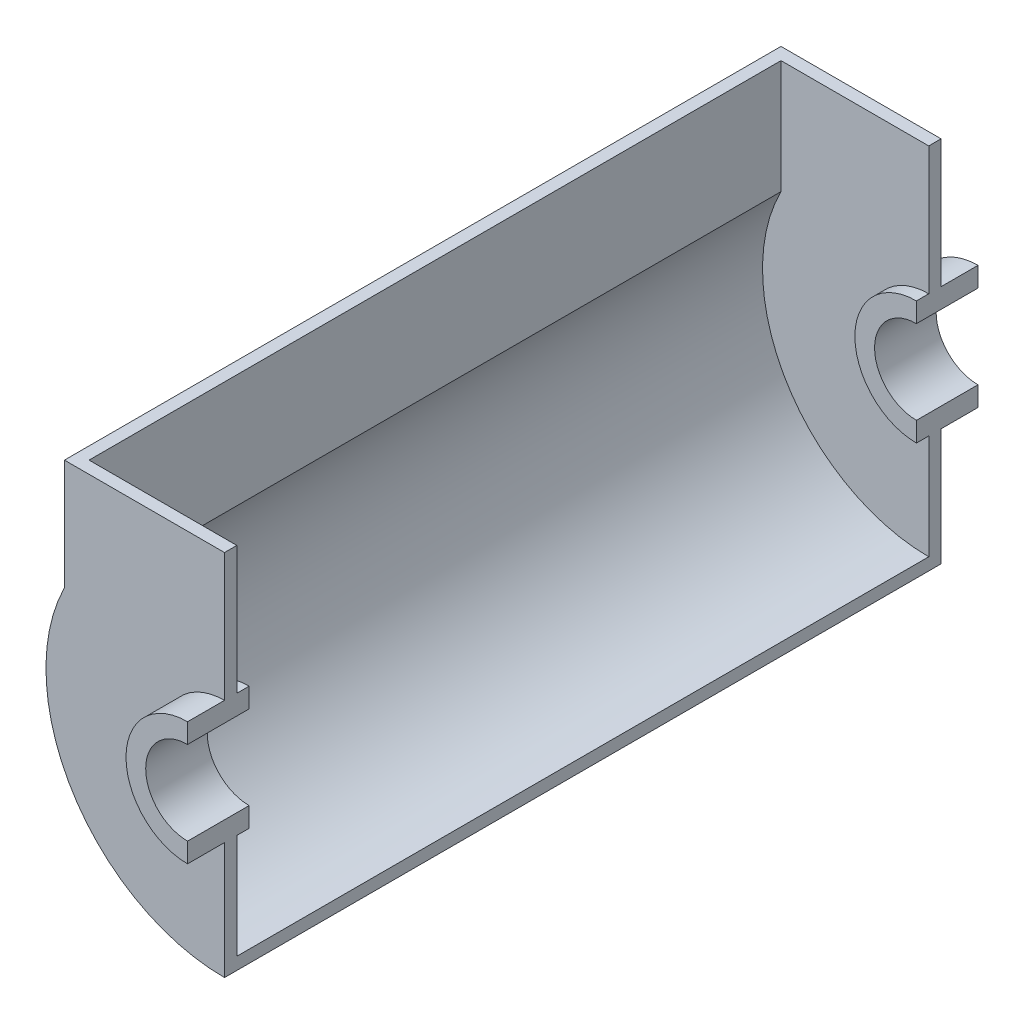
from build123d import *

# Parameters (mm, degrees)
BOSS_EXTRUDE1_DEPTH      = 20
BOSS_EXTRUDE1_DEPTH_BACK = 5
BOSS_EXTRUDE2_DEPTH      = 5
BOSS_EXTRUDE4_DEPTH      = 281


with BuildPart() as part:
    # Sketch1 → Boss-Extrude1 (new body, two sides)
    with BuildSketch(Plane.XY) as boss_extrude1_sk:
        with BuildLine():
            Line((0, 25), (0, 17))
            ThreePointArc((0, 17), (-17, 0), (0, -17))
            Line((0, -17), (0, -25))
            ThreePointArc((0, -25), (-25, 0), (0, 25))
        make_face()
    extrude(amount=BOSS_EXTRUDE1_DEPTH)
    extrude(boss_extrude1_sk.sketch, amount=-BOSS_EXTRUDE1_DEPTH_BACK)

    # Sketch2 → Boss-Extrude2 (add)
    with BuildSketch(Plane.XY):
        with BuildLine():
            Line((0, 25), (0, 77))
            Line((0, 77), (-65, 77))
            Line((-65, 77), (-65, 32.113081447))
            ThreePointArc((-65, 32.113081447), (-61.581037686, -38.262590053), (0, -72.5))
            Line((0, -72.5), (0, -25))
            ThreePointArc((0, -25), (-25, 0), (0, 25))
        make_face()
    extrude(amount=BOSS_EXTRUDE2_DEPTH)


with BuildPart() as body_2:
    # Mirror2: mirrored copy
    add(part.part.mirror(Plane.XY.offset(-140.5)))


with BuildPart() as part_1:
    add(part.part)

    add(body_2.part)  # Boss-Extrude4 merges body 2
    # Sketch3 → Boss-Extrude4 (add)
    with BuildSketch(Plane(origin=(0, 0, 0), x_dir=(-1, 0, 0), z_dir=(0, 0, -1))):
        with BuildLine():
            Line((60, 77), (60, 30.923292192))
            ThreePointArc((60, 30.923292192), (57.634938288, -35.134938288), (0, -67.5))
            Line((0, -67.5), (0, -72.5))
            ThreePointArc((0, -72.5), (61.581037686, -38.262590053), (65, 32.113081447))
            Line((65, 32.113081447), (65, 77))
            Line((65, 77), (60, 77))
        make_face()
    extrude(amount=BOSS_EXTRUDE4_DEPTH)


solid = part_1.part
